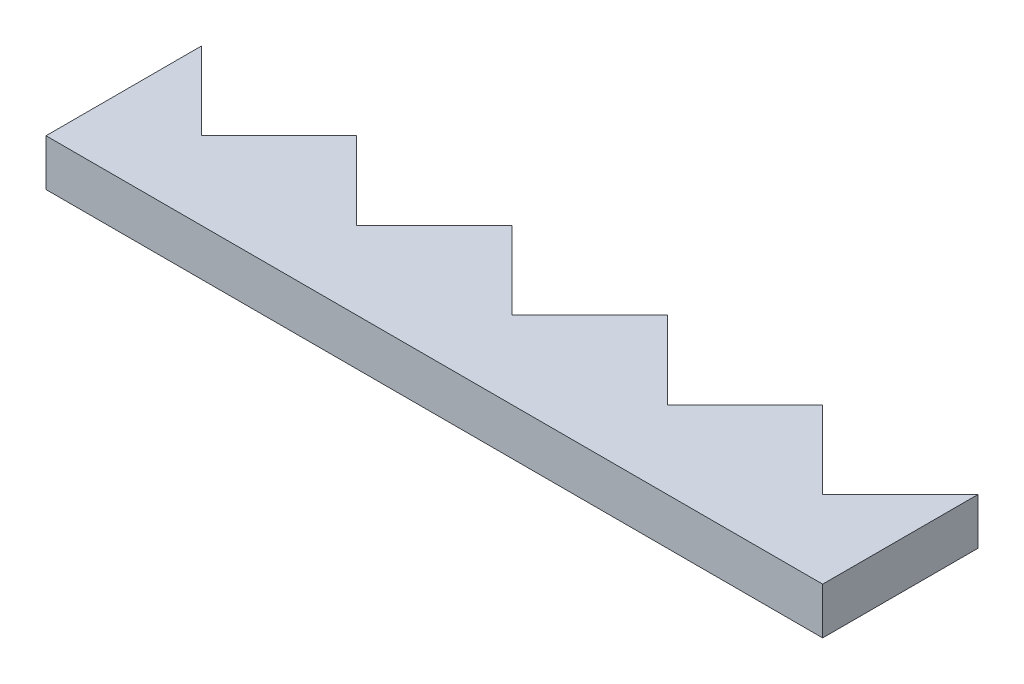
from build123d import *

# Parameters (mm, degrees)
BOSS_EXTRUDE1_DEPTH = 3


with BuildPart() as part:
    # Sketch1 → Boss-Extrude1 (new body)
    with BuildSketch(Plane(origin=(0, 0.330251497, 0), x_dir=(1, 0, 0), z_dir=(0, 1, 0))):
        Polygon((0, 0), (0, 10), (5, 5), (10, 10), (15, 5), (20, 10), (25, 5), (30, 10), (35, 5), (40, 10), (45, 5), (50, 10), (50, 0), align=None)
    extrude(amount=BOSS_EXTRUDE1_DEPTH)


solid = part.part
